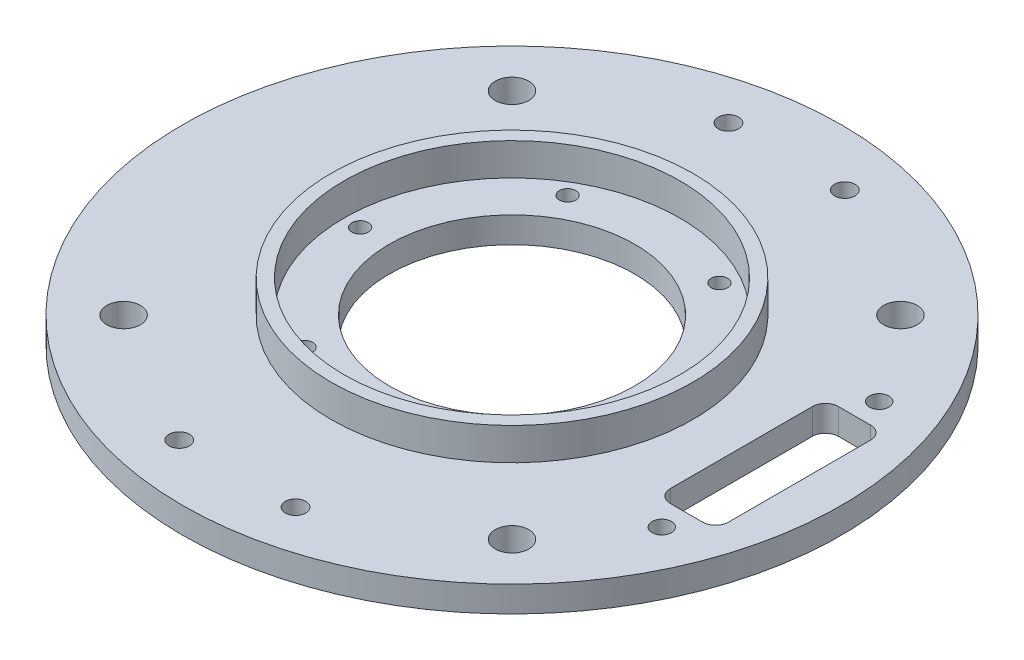
from build123d import *

# Parameters (mm, degrees)
SKETCH_1_R                  = 51
SKETCH_1_R_2                = 19
EXTRUDE_1_DEPTH             = 4
PATTERN_CIRCULAR_1_COUNT    = 6
HOLE_WIZARD_M32_D           = 3.15
PATTERN_LINEAR_1_COUNT      = 2
PATTERN_LINEAR_1_PITCH      = 18
PATTERN_LINEAR_1_COUNT_DIR2 = 2
PATTERN_LINEAR_1_PITCH_DIR2 = 85
SKETCH_14_R                 = 28
SKETCH_14_R_2               = 26
EXTRUDE_2_DEPTH             = 5
SKETCH_16_R                 = 1.5
SKETCH_16_W                 = 9
SKETCH_16_H                 = 26
CUT_EXTRUDE_1_DEPTH         = 5
FILLET_1_R                  = 2
PATTERN_CIRCULAR_2_COUNT    = 4


with BuildPart() as part:
    # Эскиз1 → Бобышка-Вытянуть1 (new body)
    with BuildSketch(Plane(origin=(0, 0, 0), x_dir=(1, 0, 0), z_dir=(0, 1, 0))):
        Circle(SKETCH_1_R)
        Circle(SKETCH_1_R_2, mode=Mode.SUBTRACT)
    extrude(amount=EXTRUDE_1_DEPTH)

    # Эскиз3 → Сверло под метчик  спиральное M2.51 (revolve, cut)
    with BuildSketch(Plane(origin=(23.5, 4, 0), x_dir=(0, 0, 1), z_dir=(1, 0, 0))):
        Polygon((0, 0), (0, 8.766097289), (1.275, 8), (1.275, 0), align=None)
    hole_wizard_m2_51 = revolve(axis=Axis((23.5, 10.35, 0), (0, -1, 0)), mode=Mode.SUBTRACT)

    # Круговой массив1: Сверло под метчик  спиральное M2.51 ×6 about axis
    pattern_circular_1_axis = Axis((0, 0, 0), (0, 1, 0))
    for i in range(1, PATTERN_CIRCULAR_1_COUNT):
        add(hole_wizard_m2_51.rotate(pattern_circular_1_axis, i * 360 / PATTERN_CIRCULAR_1_COUNT), mode=Mode.SUBTRACT)

    # Сверло под метчик  спиральное M32 (through all)
    with Locations(Plane(origin=(0, 0, 0), x_dir=(-1, 0, 0), z_dir=(0, -1, 0))):
        with Locations((-9, -42.5)):
            hole_wizard_m32 = Hole(HOLE_WIZARD_M32_D / 2)

    # Линейный массив1: Hole Wizard M32 2 × 2
    with Locations(*[(-i * PATTERN_LINEAR_1_PITCH, 0, -j * PATTERN_LINEAR_1_PITCH_DIR2) for i in range(PATTERN_LINEAR_1_COUNT) for j in range(PATTERN_LINEAR_1_COUNT_DIR2) if (i, j) != (0, 0)]):
        add(hole_wizard_m32, mode=Mode.SUBTRACT)

    # Эскиз14 → Бобышка-Вытянуть2 (add)
    with BuildSketch(Plane(origin=(0, 4, 0), x_dir=(1, 0, 0), z_dir=(0, 1, 0))):
        Circle(SKETCH_14_R)
        Circle(SKETCH_14_R_2, mode=Mode.SUBTRACT)
    extrude(amount=EXTRUDE_2_DEPTH)

    # Эскиз16 → Вырез-Вытянуть1 (cut, through all)
    with BuildSketch(Plane(origin=(0, 4, 0), x_dir=(1, 0, 0), z_dir=(0, 1, 0))):
        with Locations((40, 16.82)):
            Circle(SKETCH_16_R)
        with Locations((40, -16.82)):
            Circle(SKETCH_16_R)
        with Locations((40, 0)):
            Rectangle(SKETCH_16_W, SKETCH_16_H)
    extrude(amount=-CUT_EXTRUDE_1_DEPTH, mode=Mode.SUBTRACT)

    # Скругление1
    fillet_1_edges = [part.edges().sort_by_distance(p)[0] for p in [
        (35.5, 2, 13),
        (35.5, 2, -13),
        (44.5, 2, -13),
        (44.5, 2, 13),
    ]]
    fillet(fillet_1_edges, radius=FILLET_1_R)

    # Эскиз18 → Сверло под метчик  спиральное M51 (revolve, cut)
    with BuildSketch(Plane(origin=(-30.0520382, 4, -30.0520382), x_dir=(0, 0, 1), z_dir=(1, 0, 0))):
        Polygon((0, 0), (0, 9.562237609), (2.6, 8), (2.6, 0), align=None)
    hole_wizard_m51 = revolve(axis=Axis((-30.0520382, 10.35, -30.0520382), (0, -1, 0)), mode=Mode.SUBTRACT)

    # Круговой массив2: Сверло под метчик  спиральное M51 ×4 about axis
    pattern_circular_2_axis = Axis((0, 0, 0), (0, 1, 0))
    for i in range(1, PATTERN_CIRCULAR_2_COUNT):
        add(hole_wizard_m51.rotate(pattern_circular_2_axis, i * 360 / PATTERN_CIRCULAR_2_COUNT), mode=Mode.SUBTRACT)


solid = part.part
